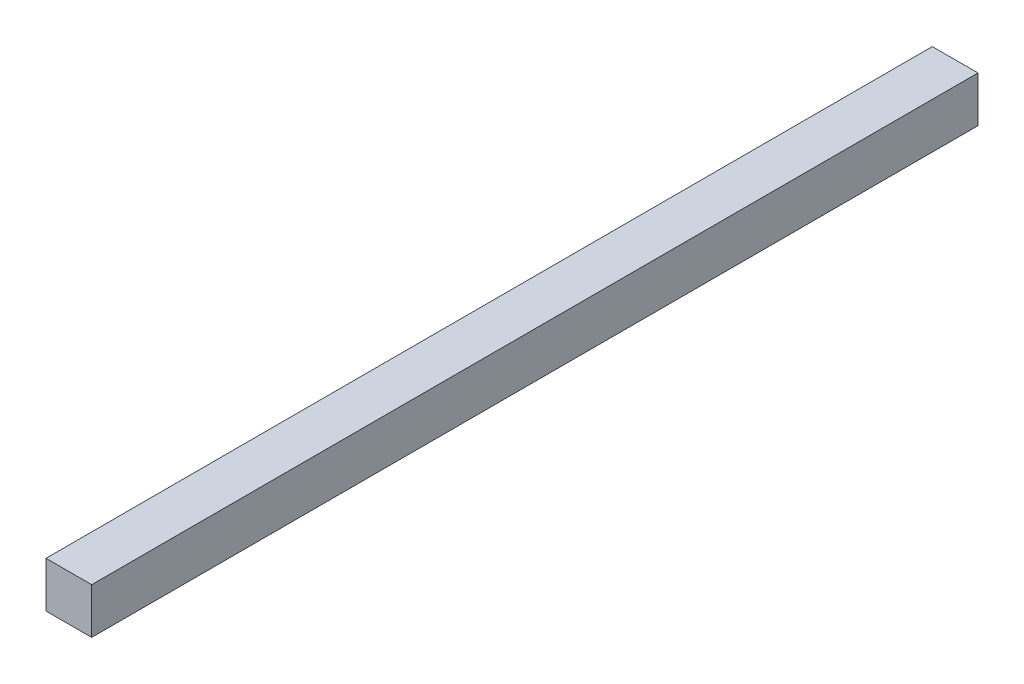
from build123d import *

# Parameters (mm, degrees)
SKETCH1_W           = 10
SKETCH1_H           = 10
BOSS_EXTRUDE1_DEPTH = 194


with BuildPart() as part:
    # Sketch1 → Boss-Extrude1 (new body)
    with BuildSketch(Plane.XY):
        Rectangle(SKETCH1_W, SKETCH1_H)
    extrude(amount=BOSS_EXTRUDE1_DEPTH)


solid = part.part
